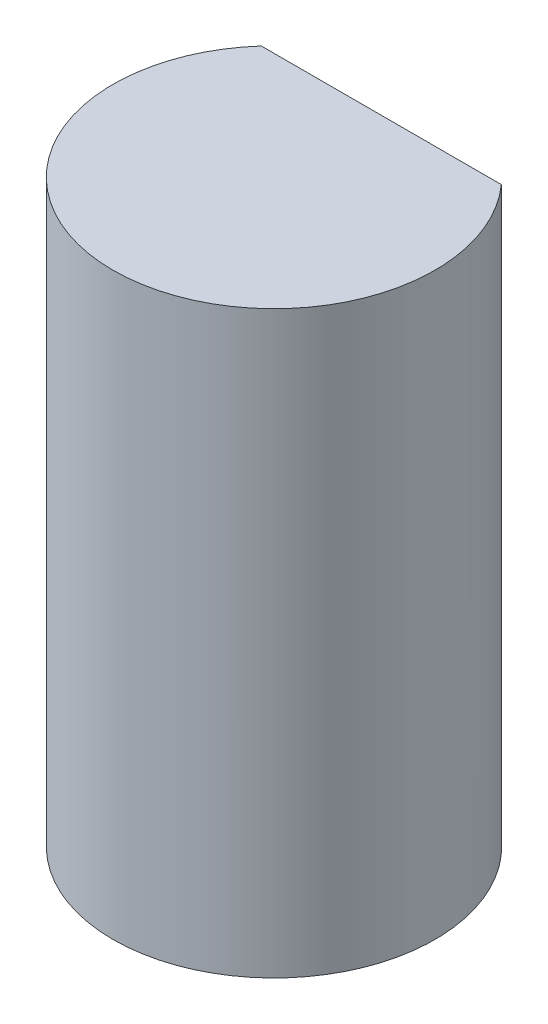
from build123d import *

# Parameters (mm, degrees)
SKETCH_1_R          = 1.5
EXTRUDE_1_DEPTH     = 5.4
CUT_EXTRUDE_1_DEPTH = 3.7


with BuildPart() as part:
    # 草图1 → 凸台-拉伸1 (new body)
    with BuildSketch(Plane(origin=(0, 0, 0), x_dir=(1, 0, 0), z_dir=(0, 1, 0))):
        Circle(SKETCH_1_R)
    extrude(amount=EXTRUDE_1_DEPTH)

    # 草图2 → 切除-拉伸1 (cut)
    with BuildSketch(Plane(origin=(0, 5.4, 0), x_dir=(1, 0, 0), z_dir=(0, 1, 0))):
        with BuildLine():
            Line((-1.118033989, 1), (1.118033989, 1))
            ThreePointArc((1.118033989, 1), (0, 1.5), (-1.118033989, 1))
        make_face()
    extrude(amount=-CUT_EXTRUDE_1_DEPTH, mode=Mode.SUBTRACT)


solid = part.part
